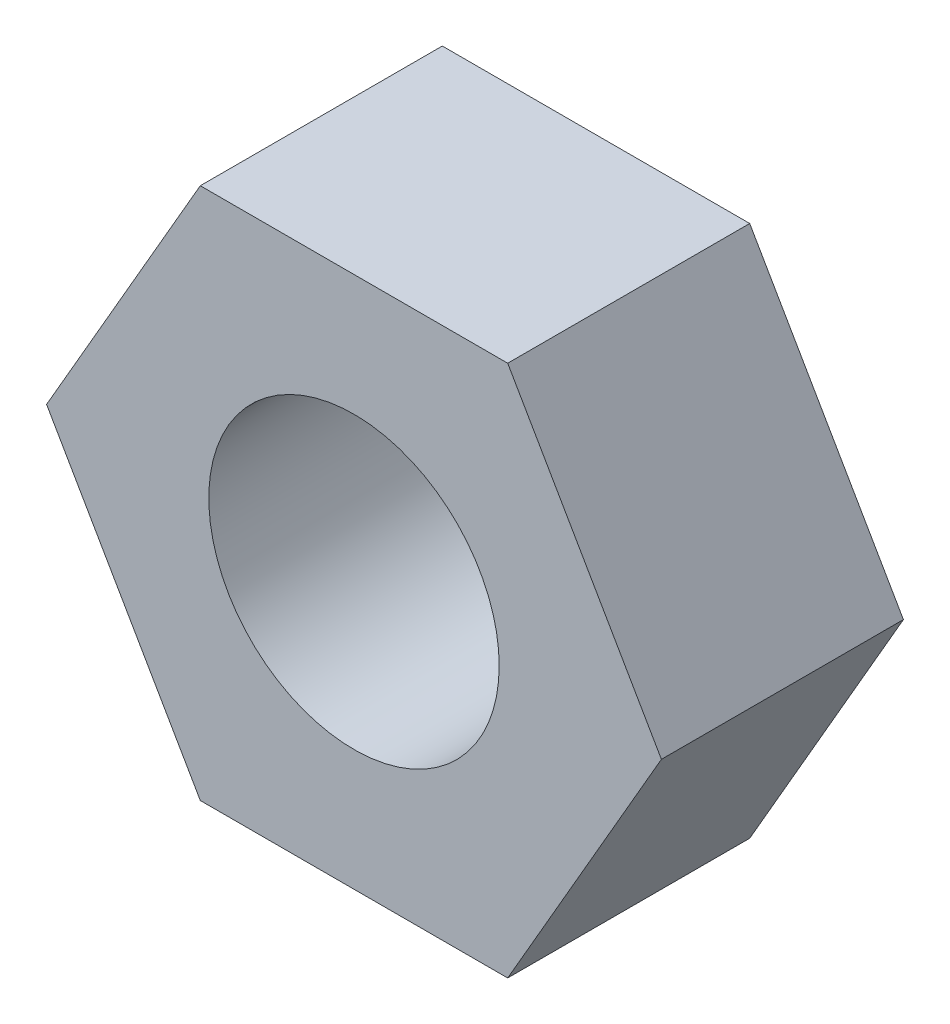
from build123d import *

# Parameters (mm, degrees)
EXTRUDE_1_DEPTH     = 2.5
SKETCH_2_R          = 1.5
CUT_EXTRUDE_1_DEPTH = 3.5


with BuildPart() as part:
    # 草图1 → 凸台-拉伸1 (new body)
    with BuildSketch(Plane.XY):
        Polygon((1.58771324, 2.75), (-1.58771324, 2.75), (-3.175426481, 0), (-1.58771324, -2.75), (1.58771324, -2.75), (3.175426481, 0), align=None)
    extrude(amount=EXTRUDE_1_DEPTH)

    # 草图2 → 切除-拉伸1 (cut, through all)
    with BuildSketch(Plane.XY.offset(2.5)):
        Circle(SKETCH_2_R)
    extrude(amount=-CUT_EXTRUDE_1_DEPTH, mode=Mode.SUBTRACT)


solid = part.part
